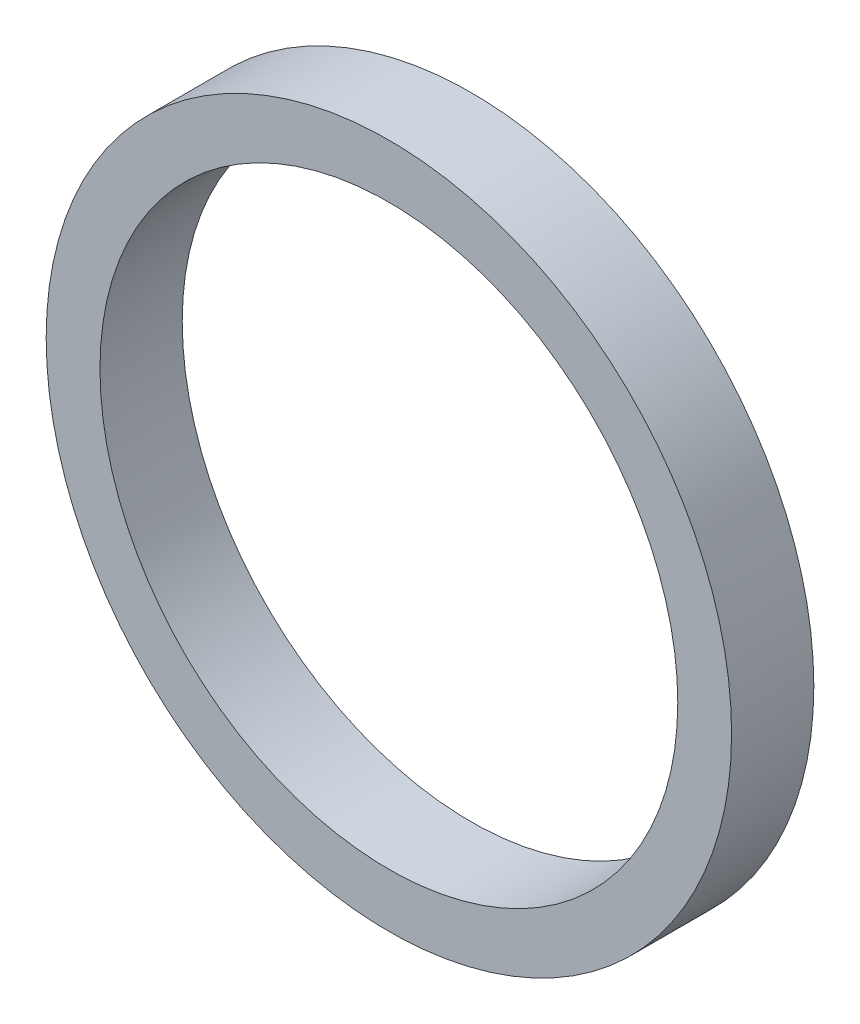
from build123d import *

# Parameters (mm, degrees)
SKETCH1_R           = 25
BOSS_EXTRUDE1_DEPTH = 6
SKETCH2_R           = 21.075
CUT_EXTRUDE1_DEPTH  = 7


with BuildPart() as part:
    # Sketch1 → Boss-Extrude1 (new body)
    with BuildSketch(Plane.XY):
        Circle(SKETCH1_R)
    extrude(amount=BOSS_EXTRUDE1_DEPTH)

    # Sketch2 → Cut-Extrude1 (cut, through all)
    with BuildSketch(Plane(origin=(0, 0, 0), x_dir=(-1, 0, 0), z_dir=(0, 0, -1))):
        Circle(SKETCH2_R)
    extrude(amount=-CUT_EXTRUDE1_DEPTH, mode=Mode.SUBTRACT)


solid = part.part
